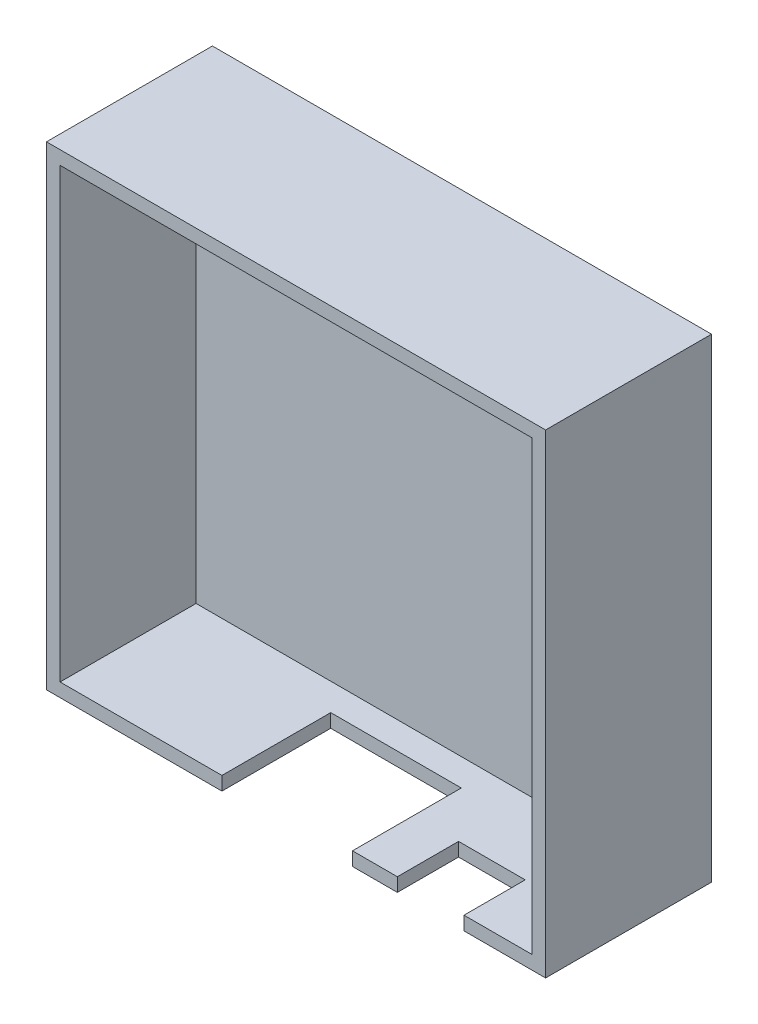
from build123d import *

# Parameters (mm, degrees)
SKETCH1_W           = 36.7
SKETCH1_H           = 34.9
SKETCH1_W_2         = 34.7
SKETCH1_H_2         = 32.9
BOSS_EXTRUDE1_DEPTH = 8
SKETCH2_W           = 36.7
SKETCH2_H           = 34.9
BOSS_EXTRUDE2_DEPTH = 4.2
SKETCH3_W           = 4.9
SKETCH3_H           = 1
CUT_EXTRUDE1_DEPTH  = 4.5
SKETCH4_W           = 9.6
SKETCH4_H           = 1
CUT_EXTRUDE2_DEPTH  = 8
SKETCH5_W           = 34.7
SKETCH5_H           = 1.5
BOSS_EXTRUDE3_DEPTH = 1.6
SKETCH6_W           = 34.7
SKETCH6_H           = 31.4
CUT_EXTRUDE3_DEPTH  = 2


with BuildPart() as part:
    # Sketch1 → Boss-Extrude1 (new body)
    with BuildSketch(Plane.XY):
        with Locations((18.35, 17.45)):
            Rectangle(SKETCH1_W, SKETCH1_H)
        with Locations((18.35, 17.45)):
            Rectangle(SKETCH1_W_2, SKETCH1_H_2, mode=Mode.SUBTRACT)
    extrude(amount=BOSS_EXTRUDE1_DEPTH)

    # Sketch2 → Boss-Extrude2 (add)
    with BuildSketch(Plane(origin=(0, 0, 0), x_dir=(-1, 0, 0), z_dir=(0, 0, -1))):
        with Locations((-18.35, 17.45)):
            Rectangle(SKETCH2_W, SKETCH2_H)
    extrude(amount=BOSS_EXTRUDE2_DEPTH)

    # Sketch3 → Cut-Extrude1 (cut)
    with BuildSketch(Plane.XY.offset(8)):
        with Locations((28.25, 0.5)):
            Rectangle(SKETCH3_W, SKETCH3_H)
    extrude(amount=-CUT_EXTRUDE1_DEPTH, mode=Mode.SUBTRACT)

    # Sketch4 → Cut-Extrude2 (cut)
    with BuildSketch(Plane.XY.offset(8)):
        with Locations((17.7, 0.5)):
            Rectangle(SKETCH4_W, SKETCH4_H)
    extrude(amount=-CUT_EXTRUDE2_DEPTH, mode=Mode.SUBTRACT)

    # Sketch5 → Boss-Extrude3 (add)
    with BuildSketch(Plane.XY):
        with Locations((18.35, 33.15)):
            Rectangle(SKETCH5_W, SKETCH5_H)
    extrude(amount=BOSS_EXTRUDE3_DEPTH)

    # Sketch6 → Cut-Extrude3 (cut)
    with BuildSketch(Plane.XY):
        with Locations((18.35, 16.7)):
            Rectangle(SKETCH6_W, SKETCH6_H)
    extrude(amount=-CUT_EXTRUDE3_DEPTH, mode=Mode.SUBTRACT)


solid = part.part
